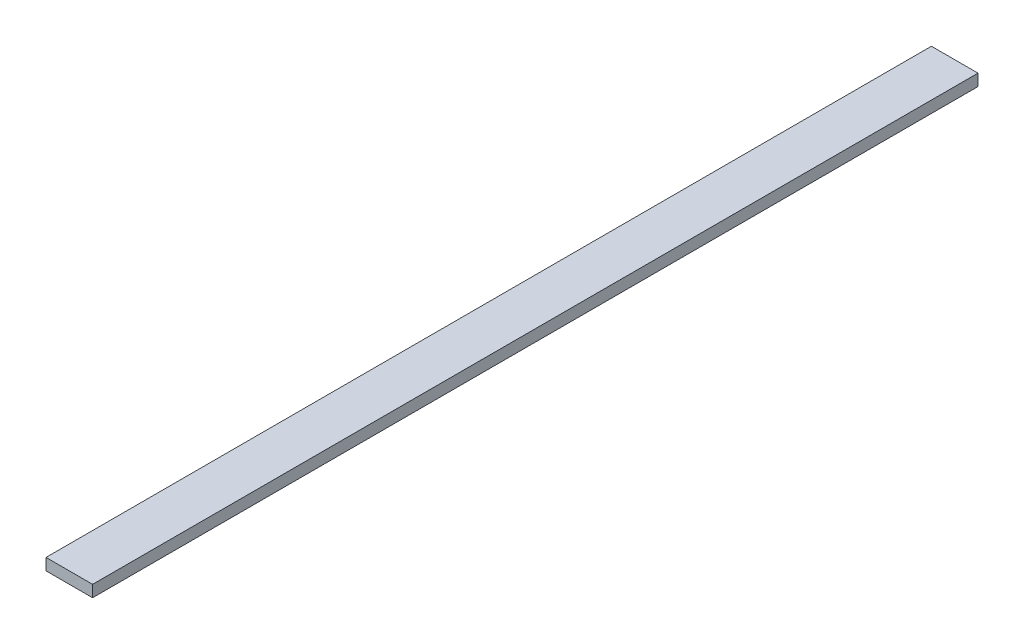
from build123d import *

# Parameters (mm, degrees)
SKETCH1_W           = 12.7
SKETCH1_H           = 3.175
BOSS_EXTRUDE1_DEPTH = 241.3


with BuildPart() as part:
    # Sketch1 → Boss-Extrude1 (new body)
    with BuildSketch(Plane.XY):
        with Locations((6.35, 1.5875)):
            Rectangle(SKETCH1_W, SKETCH1_H)
    extrude(amount=BOSS_EXTRUDE1_DEPTH)


solid = part.part
